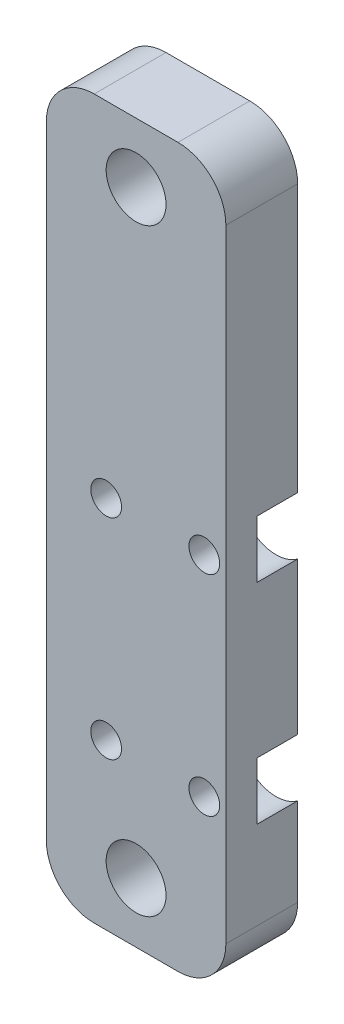
from build123d import *

# Parameters (mm, degrees)
SKETCH1_W                                      = 19.05
SKETCH1_H                                      = 76.2
BOSS_EXTRUDE1_DEPTH                            = 7.62
F_1_4_0_25_DIAMETER_HOLE1_D                    = 6.35
F_1_4_0_25_DIAMETER_HOLE1_DEPTH                = 25.4
F_1_4_0_25_DIAMETER_HOLE1_TIP                  = 1.907732465
CBORE_FOR_4_SOCKET_HEAD_CAP_SCREW5_D           = 3.2639
CBORE_FOR_4_SOCKET_HEAD_CAP_SCREW5_CBORE_D     = 7.62
CBORE_FOR_4_SOCKET_HEAD_CAP_SCREW5_CBORE_DEPTH = 4.318
FILLET1_R                                      = 5.08


with BuildPart() as part:
    # Sketch1 → Boss-Extrude1 (new body)
    with BuildSketch(Plane.XY):
        with Locations((-4.445, -9.525)):
            Rectangle(SKETCH1_W, SKETCH1_H)
    extrude(amount=BOSS_EXTRUDE1_DEPTH)

    # 1/4 (0.25) Diameter Hole1
    with Locations(Plane.XY.offset(7.62)):
        with Locations((-4.445, 22.225), (-4.445, -41.275)):
            Hole(F_1_4_0_25_DIAMETER_HOLE1_D / 2, depth=F_1_4_0_25_DIAMETER_HOLE1_DEPTH)
            with Locations((0, 0, -(F_1_4_0_25_DIAMETER_HOLE1_DEPTH + F_1_4_0_25_DIAMETER_HOLE1_TIP / 2))):  # 118° drill point
                Cone(0, F_1_4_0_25_DIAMETER_HOLE1_D / 2, F_1_4_0_25_DIAMETER_HOLE1_TIP, mode=Mode.SUBTRACT)

    # CBORE for #4 Socket Head Cap Screw5 (through all)
    with Locations(Plane(origin=(-2.017261163, -3.813643011, 0), x_dir=(1, 0, 0), z_dir=(0, 0, -1))):
        with Locations((-5.602738837, 4.123856989), (-5.602738837, 26.348856989), (4.811261163, 26.348856989), (4.811261163, 4.123856989)):
            CounterBoreHole(CBORE_FOR_4_SOCKET_HEAD_CAP_SCREW5_D / 2, CBORE_FOR_4_SOCKET_HEAD_CAP_SCREW5_CBORE_D / 2, CBORE_FOR_4_SOCKET_HEAD_CAP_SCREW5_CBORE_DEPTH)

    # Fillet1
    fillet1_edges = [part.edges().sort_by_distance(p)[0] for p in [
        (-13.97, 28.575, 3.81),
        (5.08, 28.575, 3.81),
        (5.08, -47.625, 3.81),
        (-13.97, -47.625, 3.81),
    ]]
    fillet(fillet1_edges, radius=FILLET1_R)


solid = part.part
